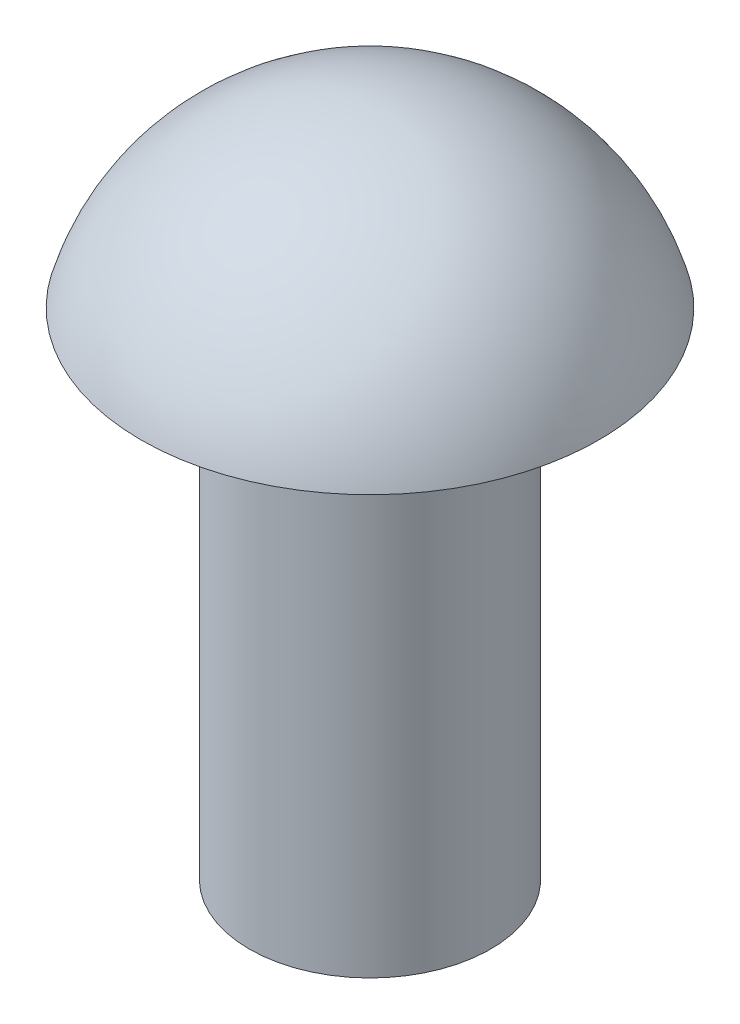
from build123d import *


with BuildPart() as part:
    # Sketch1 → Revolve2 (revolve)
    with BuildSketch(Plane(origin=(0, 0, 0), x_dir=(0, 0, -1), z_dir=(1, 0, 0))):
        with BuildLine():
            Line((0, -5.4), (0.975, -5.4))
            Line((0.975, -5.4), (0.975, -1.4))
            Line((0.975, -1.4), (1.85, -1.4))
            ThreePointArc((1.85, -1.4), (1.160010776, -0.389450046), (0, 0))
            Line((0, 0), (0, -5.4))
        make_face()
    revolve(axis=Axis((0, 0, 0), (0, -1, 0)))


solid = part.part
